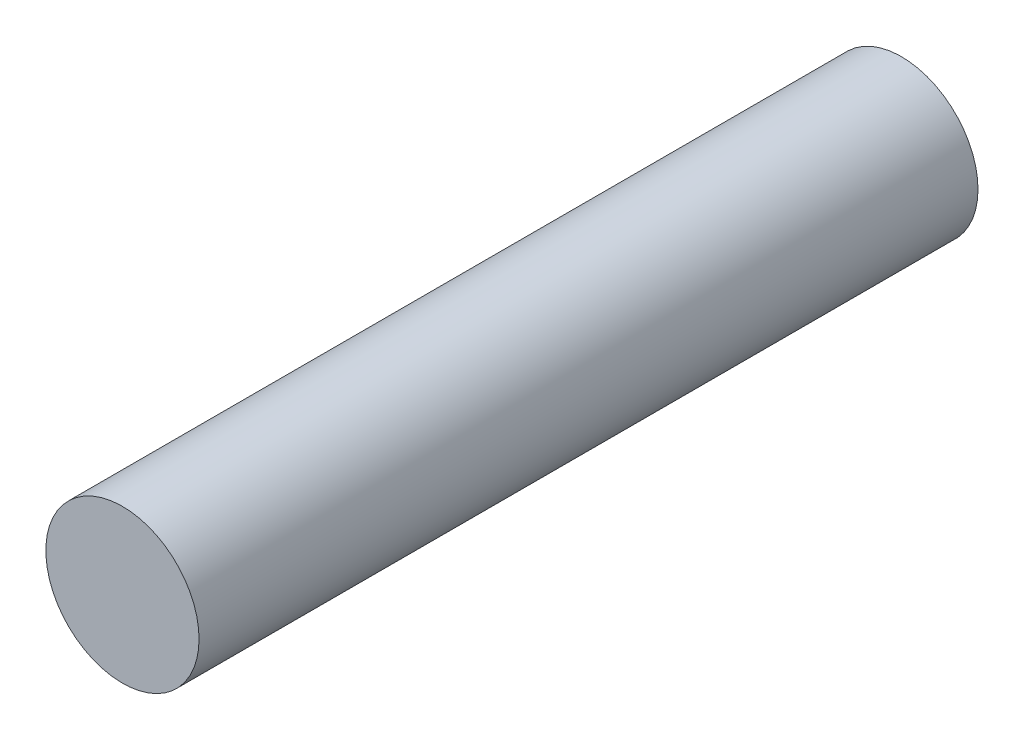
from build123d import *

# Parameters (mm, degrees)
SKETCH1_R           = 2.95
BOSS_EXTRUDE1_DEPTH = 30
CUT_EXTRUDE1_DEPTH  = 7


with BuildPart() as part:
    # Sketch1 → Boss-Extrude1 (new body)
    with BuildSketch(Plane.XY):
        Circle(SKETCH1_R)
    extrude(amount=BOSS_EXTRUDE1_DEPTH)

    # Sketch2 → Cut-Extrude1 (cut)
    with BuildSketch(Plane(origin=(0, 0, 0), x_dir=(-1, 0, 0), z_dir=(0, 0, -1))):
        with BuildLine():
            Line((-1.619397374, 1.4), (1.619397374, 1.4))
            ThreePointArc((1.619397374, 1.4), (0, -2.140665283), (-1.619397374, 1.4))
        make_face()
    extrude(amount=-CUT_EXTRUDE1_DEPTH, mode=Mode.SUBTRACT)


solid = part.part
